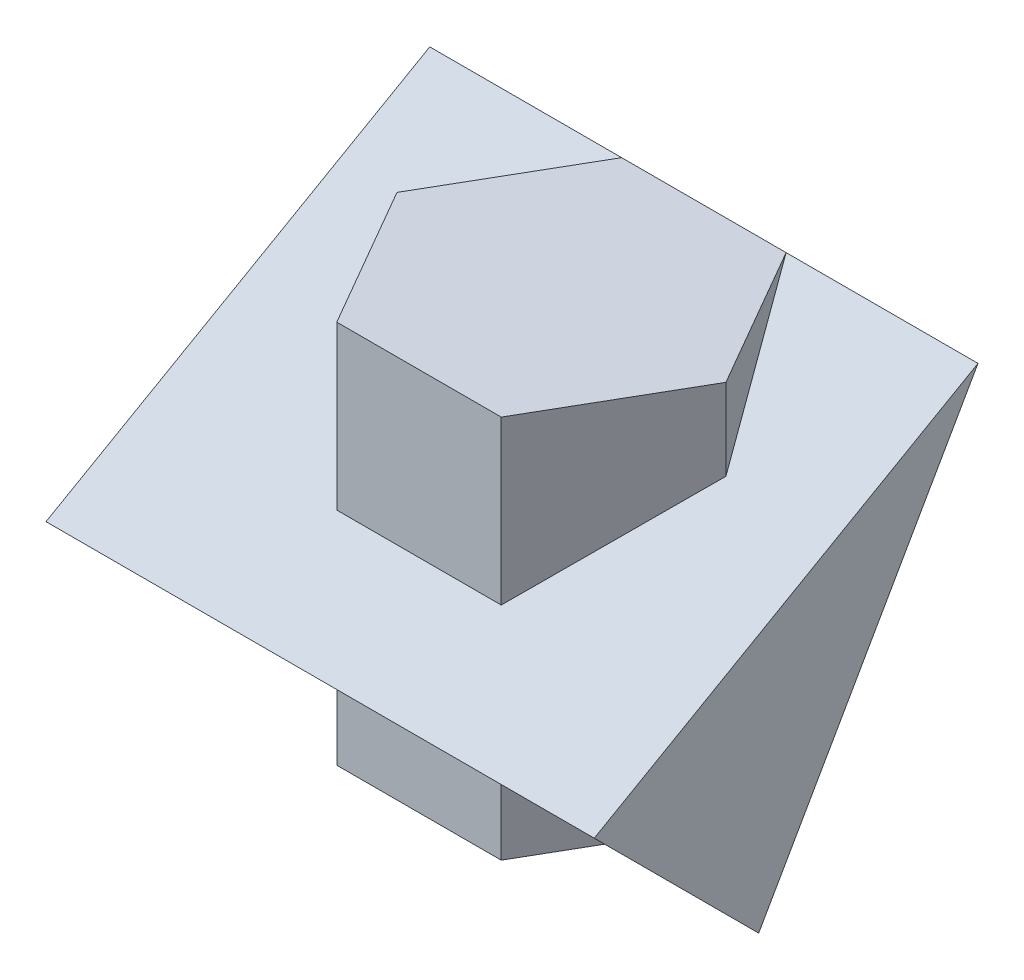
from build123d import *

# Parameters (mm, degrees)
HEXAGONAL_PRISM_DEPTH       = 70
TRIANGULAR_PRISM_DEPTH      = 50
TRIANGULAR_PRISM_DEPTH_BACK = 50


with BuildPart() as part:
    # Sketch1 → Hexagonal Prism (new body)
    with BuildSketch(Plane(origin=(0, 0, 0), x_dir=(1, 0, 0), z_dir=(0, 1, 0))):
        Polygon((15, -51.961524227), (30, -25.980762114), (15, 0), (-15, 0), (-30, -25.980762114), (-15, -51.961524227), align=None)
    extrude(amount=HEXAGONAL_PRISM_DEPTH)

    # Sketch2 → Triangular Prism (add, two sides)
    with BuildSketch(Plane(origin=(0, 0, 0), x_dir=(0, 0, -1), z_dir=(1, 0, 0))) as triangular_prism_sk:
        Polygon((0, 70), (-40, 0), (-70, 30), align=None)
    extrude(amount=TRIANGULAR_PRISM_DEPTH)
    extrude(triangular_prism_sk.sketch, amount=-TRIANGULAR_PRISM_DEPTH_BACK)


solid = part.part
